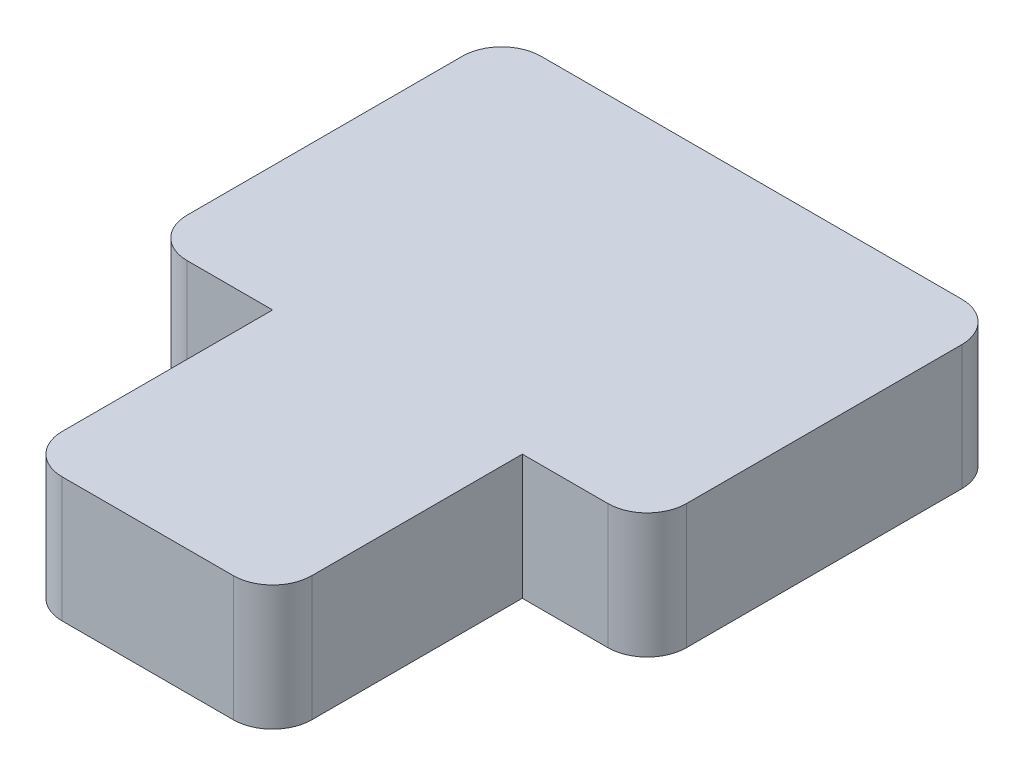
from build123d import *

# Parameters (mm, degrees)
MOTORSUPPORT_EXTRUDE_DEPTH  = 3.175
MOTORSUPPORT_BOTTOMFILLET_R = 1


with BuildPart() as part:
    # Sketch1 → MotorSupport_Extrude (new body)
    with BuildSketch(Plane(origin=(0, 0, 0), x_dir=(1, 0, 0), z_dir=(0, 1, 0))):
        Polygon((0, 0), (6.35, 0), (6.35, 6.35), (9.525, 6.35), (9.525, 15.35), (-3.175, 15.35), (-3.175, 6.35), (0, 6.35), align=None)
    extrude(amount=MOTORSUPPORT_EXTRUDE_DEPTH)

    # MotorSupport_BottomFillet
    motorsupport_bottomfillet_edges = [part.edges().sort_by_distance(p)[0] for p in [
        (-3.175, 1.5875, -6.35),
        (-3.175, 1.5875, -15.35),
        (9.525, 1.5875, -15.35),
        (9.525, 1.5875, -6.35),
        (6.35, 1.5875, 0),
        (0, 1.5875, 0),
    ]]
    fillet(motorsupport_bottomfillet_edges, radius=MOTORSUPPORT_BOTTOMFILLET_R)


solid = part.part
